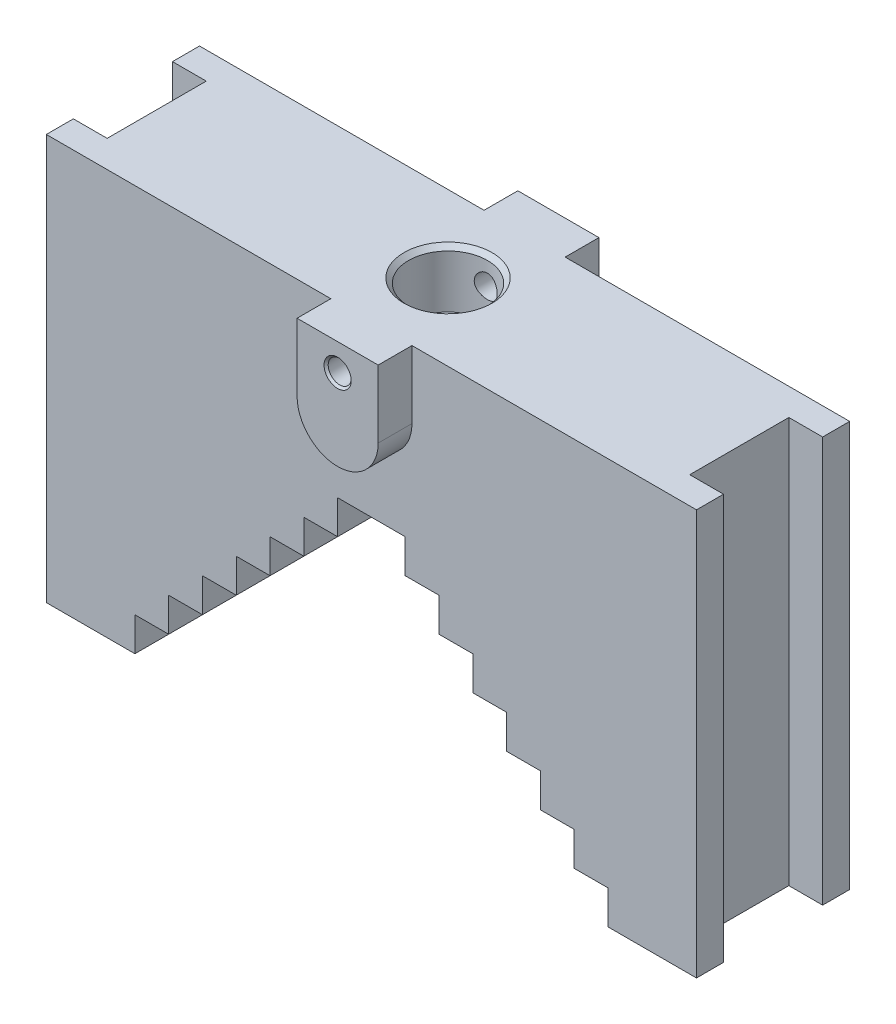
from build123d import *

# Parameters (mm, degrees)
SKETCH1_W                    = 288.63
SKETCH1_H                    = 180
BOSS_EXTRUDE1_DEPTH          = 68
CUT_EXTRUDE5_DEPTH           = 69
BOSS_EXTRUDE2_DEPTH          = 15
BOSS_EXTRUDE3_DEPTH          = 15
SKETCH9_W                    = 44
SKETCH9_H                    = 180
CUT_EXTRUDE6_DEPTH           = 15
SKETCH10_W                   = 44
SKETCH10_H                   = 180
CUT_EXTRUDE7_DEPTH           = 15
M12_TAPPED_HOLE1_D           = 10.2
M12_TAPPED_HOLE1_DEPTH       = 98
M12_TAPPED_HOLE1_CSINK_D     = 12.05
M12_TAPPED_HOLE1_CSINK_ANGLE = 90
M12_TAPPED_HOLE2_D           = 10.2
M12_TAPPED_HOLE2_DEPTH       = 98
M12_TAPPED_HOLE2_CSINK_D     = 12.05
M12_TAPPED_HOLE2_CSINK_ANGLE = 90
M39_TAPPED_HOLE1_D           = 35
M39_TAPPED_HOLE1_DEPTH       = 25.484939167
M39_TAPPED_HOLE1_CSINK_D     = 39.05
M39_TAPPED_HOLE1_CSINK_ANGLE = 90
M39_TAPPED_HOLE1_TIP         = 10.515060833


with BuildPart() as part:
    # Sketch1 → Boss-Extrude1 (new body)
    with BuildSketch(Plane.XY):
        Rectangle(SKETCH1_W, SKETCH1_H)
    extrude(amount=BOSS_EXTRUDE1_DEPTH)

    # Sketch3 → Cut-Extrude5 (cut, through all)
    with BuildSketch(Plane.XY.offset(68)):
        Polygon((15, 15), (-15, 15), (-15, 0), (-30, 0), (-30, -15), (-45, -15), (-45, -30), (-60, -30), (-60, -45), (-75, -45), (-75, -60), (-90, -60), (-90, -75), (-105, -75), (-105, -90), (105, -90), (105, -75), (90, -75), (90, -60), (75, -60), (75, -45), (60, -45), (60, -30), (45, -30), (45, -15), (30, -15), (30, 0), (15, 0), align=None)
    extrude(amount=-CUT_EXTRUDE5_DEPTH, mode=Mode.SUBTRACT)

    # Sketch7 → Boss-Extrude2 (add)
    with BuildSketch(Plane.XY.offset(68)):
        with BuildLine():
            Line((-18, 90), (-18, 60))
            ThreePointArc((-18, 60), (0, 42), (18, 60))
            Line((18, 60), (18, 90))
            Line((18, 90), (-18, 90))
        make_face()
    extrude(amount=BOSS_EXTRUDE2_DEPTH)

    # Sketch8 → Boss-Extrude3 (add)
    with BuildSketch(Plane(origin=(0, 0, 0), x_dir=(-1, 0, 0), z_dir=(0, 0, -1))):
        with BuildLine():
            Line((-18, 90), (18, 90))
            Line((18, 90), (18, 60))
            ThreePointArc((18, 60), (0, 42), (-18, 60))
            Line((-18, 60), (-18, 90))
        make_face()
    extrude(amount=BOSS_EXTRUDE3_DEPTH)

    # Sketch9 → Cut-Extrude6 (cut)
    with BuildSketch(Plane.ZY.offset(144.315)):
        with Locations((34, 0)):
            Rectangle(SKETCH9_W, SKETCH9_H)
    extrude(amount=-CUT_EXTRUDE6_DEPTH, mode=Mode.SUBTRACT)

    # Sketch10 → Cut-Extrude7 (cut)
    with BuildSketch(Plane(origin=(144.315, 0, 0), x_dir=(0, 0, -1), z_dir=(1, 0, 0))):
        with Locations((-34, 0)):
            Rectangle(SKETCH10_W, SKETCH10_H)
    extrude(amount=-CUT_EXTRUDE7_DEPTH, mode=Mode.SUBTRACT)

    # M12 Tapped Hole1
    with Locations(Plane.XY.offset(83)):
        with Locations((0, 78)):
            CounterSinkHole(M12_TAPPED_HOLE1_D / 2, M12_TAPPED_HOLE1_CSINK_D / 2, depth=M12_TAPPED_HOLE1_DEPTH, counter_sink_angle=M12_TAPPED_HOLE1_CSINK_ANGLE)

    # M12 Tapped Hole2
    with Locations(Plane(origin=(0, 0, -15), x_dir=(-1, 0, 0), z_dir=(0, 0, -1))):
        with Locations((0, 78)):
            CounterSinkHole(M12_TAPPED_HOLE2_D / 2, M12_TAPPED_HOLE2_CSINK_D / 2, depth=M12_TAPPED_HOLE2_DEPTH, counter_sink_angle=M12_TAPPED_HOLE2_CSINK_ANGLE)

    # M39 Tapped Hole1
    with Locations(Plane(origin=(0, 90, 0), x_dir=(1, 0, 0), z_dir=(0, 1, 0))):
        with Locations((0, -34)):
            CounterSinkHole(M39_TAPPED_HOLE1_D / 2, M39_TAPPED_HOLE1_CSINK_D / 2, depth=M39_TAPPED_HOLE1_DEPTH, counter_sink_angle=M39_TAPPED_HOLE1_CSINK_ANGLE)
            with Locations((0, 0, -(M39_TAPPED_HOLE1_DEPTH + M39_TAPPED_HOLE1_TIP / 2))):  # 118° drill point
                Cone(0, M39_TAPPED_HOLE1_D / 2, M39_TAPPED_HOLE1_TIP, mode=Mode.SUBTRACT)


solid = part.part
